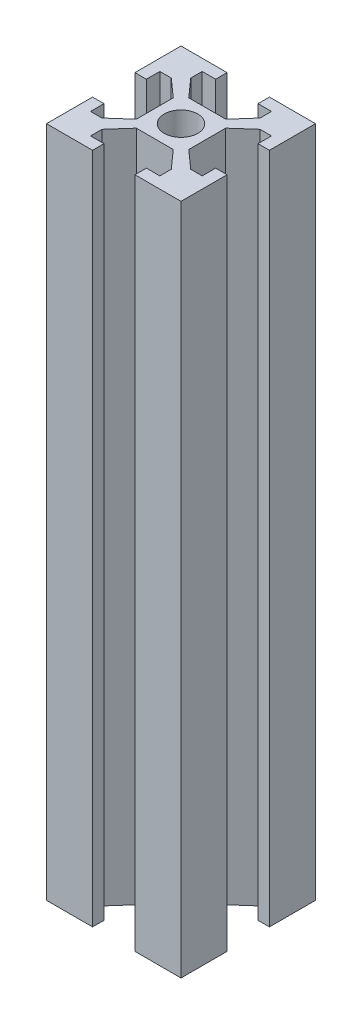
from build123d import *

# Parameters (mm, degrees)
SKETCH_1_W          = 20
SKETCH_1_H          = 20
EXTRUDE_1_DEPTH     = 100
SKETCH_2_R          = 2.5
CUT_EXTRUDE_1_DEPTH = 101


with BuildPart() as part:
    # 草图1 → 凸台-拉伸1 (new body)
    with BuildSketch(Plane(origin=(0, 0, 0), x_dir=(1, 0, 0), z_dir=(0, 1, 0))):
        Rectangle(SKETCH_1_W, SKETCH_1_H)
    extrude(amount=EXTRUDE_1_DEPTH)

    # 草图2 → 切除-拉伸1 (cut, through all)
    with BuildSketch(Plane(origin=(0, 100, 0), x_dir=(1, 0, 0), z_dir=(0, 1, 0))):
        Circle(SKETCH_2_R)
        Polygon((-3.15, 10), (-3.15, 8.3), (-5.15, 8.3), (-5.15, 6.6), (-2.75, 3.9), (2.75, 3.9), (5.15, 6.6), (5.15, 8.3), (3.15, 8.3), (3.15, 10), align=None)
        Polygon((3.9, 2.75), (3.9, -2.75), (6.6, -5.15), (8.3, -5.15), (8.3, -3.15), (10, -3.15), (10, 3.15), (8.3, 3.15), (8.3, 5.15), (6.6, 5.15), align=None)
        Polygon((2.75, -3.9), (-2.75, -3.9), (-5.15, -6.6), (-5.15, -8.3), (-3.15, -8.3), (-3.15, -10), (3.15, -10), (3.15, -8.3), (5.15, -8.3), (5.15, -6.6), align=None)
        Polygon((-3.9, -2.75), (-3.9, 2.75), (-6.6, 5.15), (-8.3, 5.15), (-8.3, 3.15), (-10, 3.15), (-10, -3.15), (-8.3, -3.15), (-8.3, -5.15), (-6.6, -5.15), align=None)
    extrude(amount=-CUT_EXTRUDE_1_DEPTH, mode=Mode.SUBTRACT)


solid = part.part
